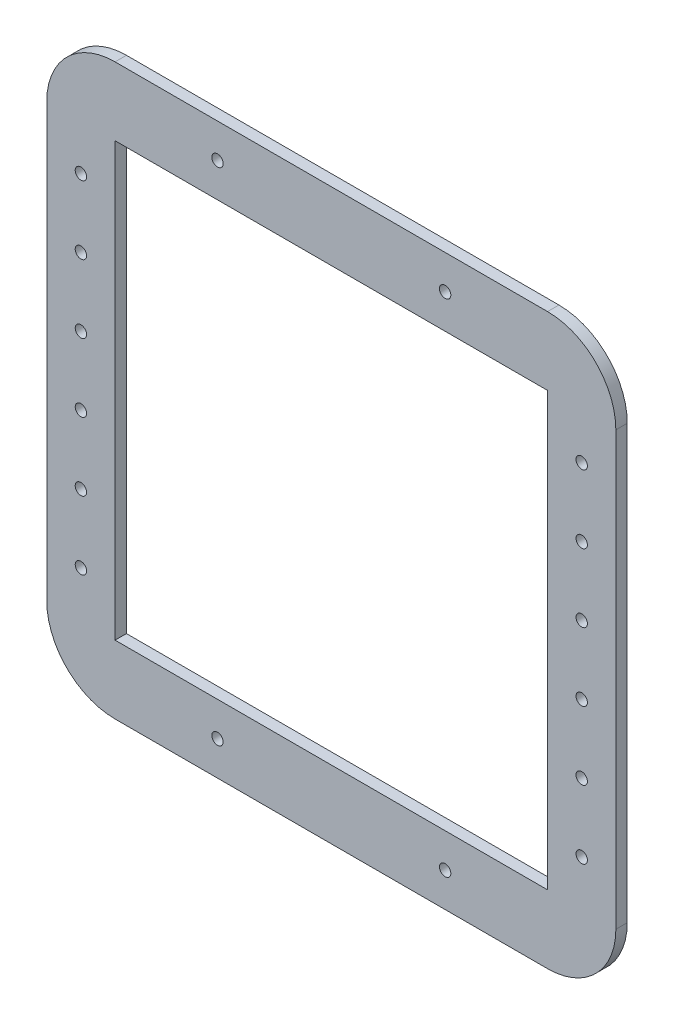
from build123d import *

# Parameters (mm, degrees)
SKETCH1_W           = 190
SKETCH1_H           = 190
BOSS_EXTRUDE1_DEPTH = 5
SKETCH2_R           = 2.5
CUT_EXTRUDE1_DEPTH  = 177.847391838
LPATTERN1_COUNT     = 6
LPATTERN1_PITCH     = 30
SKETCH3_R           = 2.5
CUT_EXTRUDE2_DEPTH  = 177.847391838


with BuildPart() as part:
    # Sketch1 → Boss-Extrude1 (new body)
    with BuildSketch(Plane.XY):
        with BuildLine():
            Line((-95, 125), (95, 125))
            ThreePointArc((95, 125), (116.213203436, 116.213203436), (125, 95))
            Line((125, 95), (125, -95))
            ThreePointArc((125, -95), (116.213203436, -116.213203436), (95, -125))
            Line((95, -125), (-95, -125))
            ThreePointArc((-95, -125), (-116.213203436, -116.213203436), (-125, -95))
            Line((-125, -95), (-125, 95))
            ThreePointArc((-125, 95), (-116.213203436, 116.213203436), (-95, 125))
        make_face()
        Rectangle(SKETCH1_W, SKETCH1_H, mode=Mode.SUBTRACT)
    extrude(amount=BOSS_EXTRUDE1_DEPTH)

    # Sketch2 → Cut-Extrude1 (cut, through all)
    with BuildSketch(Plane.XY.offset(5)):
        with Locations((-110, 75)):
            Circle(SKETCH2_R)
        with Locations((110, 75)):
            Circle(SKETCH2_R)
    cut_extrude1 = extrude(amount=-CUT_EXTRUDE1_DEPTH, mode=Mode.SUBTRACT)

    # LPattern1: Cut-Extrude1 ×6
    with Locations(*[(0, -i * LPATTERN1_PITCH, 0) for i in range(1, LPATTERN1_COUNT)]):
        add(cut_extrude1, mode=Mode.SUBTRACT)

    # Sketch3 → Cut-Extrude2 (cut, through all)
    with BuildSketch(Plane.XY.offset(5)):
        with Locations((-50, 110)):
            Circle(SKETCH3_R)
        with Locations(Location((50, 110, 0), (0, 0, 180))):
            Circle(SKETCH3_R)
        with Locations(Location((-50, -110, 0), (0, 0, 180))):
            Circle(SKETCH3_R)
        with Locations((50, -110)):
            Circle(SKETCH3_R)
    extrude(amount=-CUT_EXTRUDE2_DEPTH, mode=Mode.SUBTRACT)


solid = part.part
